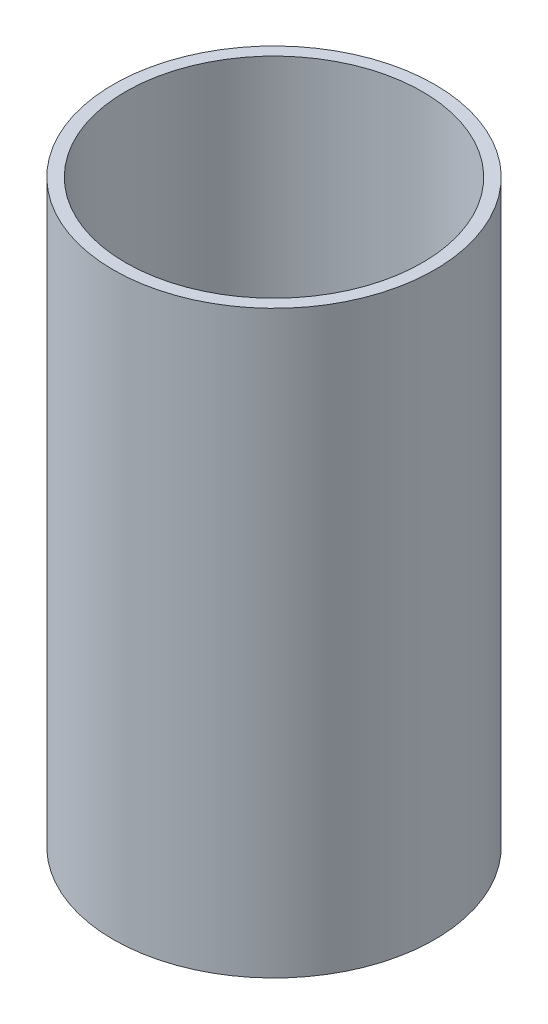
from build123d import *

# Parameters (mm, degrees)
SKETCH1_R           = 82.55
SKETCH1_R_2         = 76.2
BOSS_EXTRUDE1_DEPTH = 149


with BuildPart() as part:
    # Sketch1 → Boss-Extrude1 (new body, symmetric)
    with BuildSketch(Plane(origin=(0, 0, 0), x_dir=(1, 0, 0), z_dir=(0, 1, 0))):
        Circle(SKETCH1_R)
        Circle(SKETCH1_R_2, mode=Mode.SUBTRACT)
    extrude(amount=BOSS_EXTRUDE1_DEPTH, both=True)


solid = part.part
